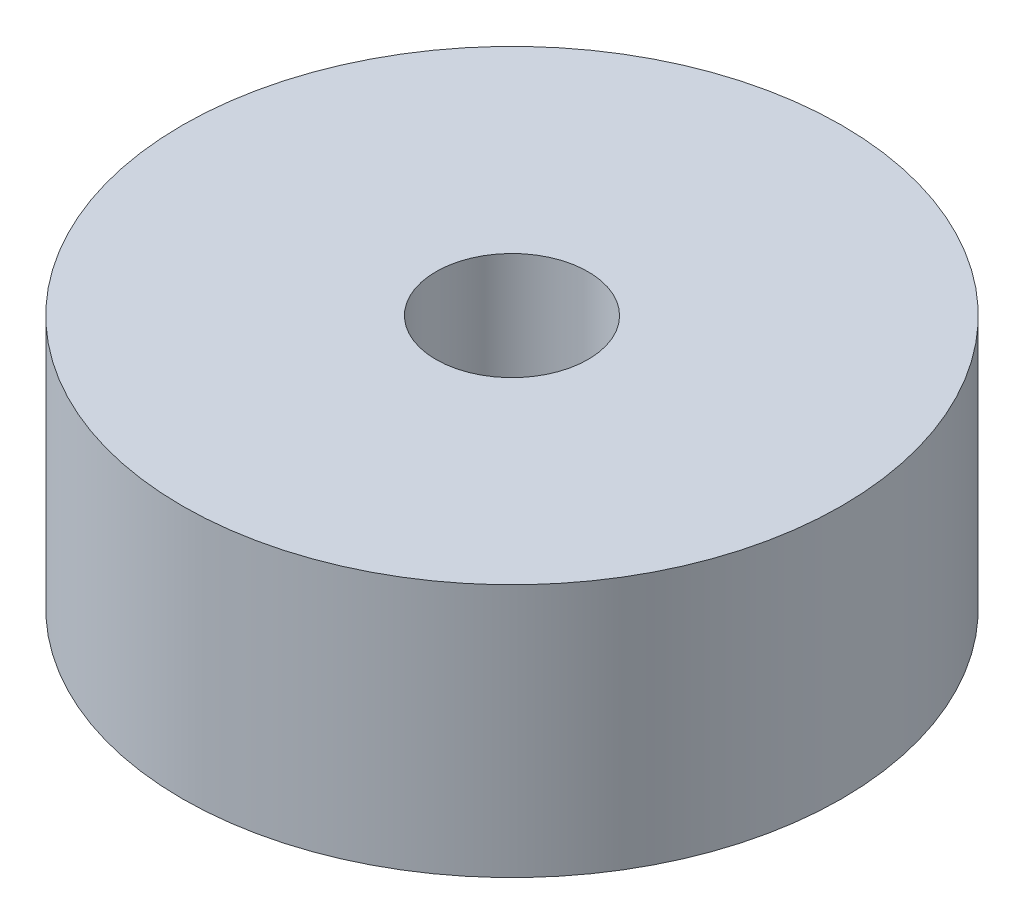
from build123d import *

# Parameters (mm, degrees)
SKETCH1_R           = 6.5
SKETCH1_R_2         = 1.5
BOSS_EXTRUDE1_DEPTH = 5


with BuildPart() as part:
    # Sketch1 → Boss-Extrude1 (new body)
    with BuildSketch(Plane(origin=(0, 0, 0), x_dir=(1, 0, 0), z_dir=(0, 1, 0))):
        Circle(SKETCH1_R)
        Circle(SKETCH1_R_2, mode=Mode.SUBTRACT)
    extrude(amount=BOSS_EXTRUDE1_DEPTH)


solid = part.part
